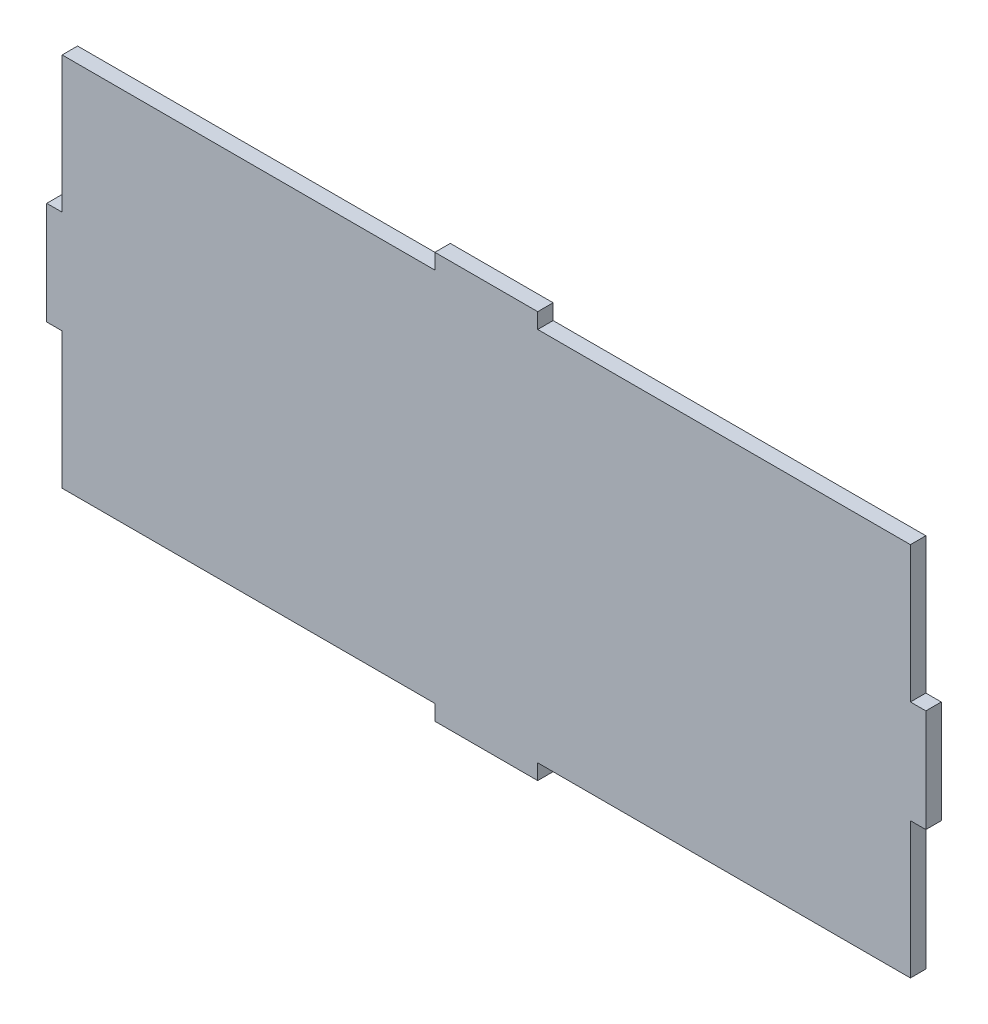
from build123d import *

# Parameters (mm, degrees)
ESBO_O1_W                = 165
ESBO_O1_H                = 73
ESBO_O1_W_2              = 20
ESBO_O1_H_2              = 3
ESBO_O1_W_3              = 3
ESBO_O1_H_3              = 20
RESSALTO_EXTRUS_O1_DEPTH = 3


with BuildPart() as part:
    # Esboço1 → Ressalto-extrusão1 (new body)
    with BuildSketch(Plane.XY):
        Rectangle(ESBO_O1_W, ESBO_O1_H)
        with Locations((0, 38)):
            Rectangle(ESBO_O1_W_2, ESBO_O1_H_2)
        with Locations((-84, 0)):
            Rectangle(ESBO_O1_W_3, ESBO_O1_H_3)
        with Locations((84, 0)):
            Rectangle(ESBO_O1_W_3, ESBO_O1_H_3)
        with Locations((0, -38)):
            Rectangle(ESBO_O1_W_2, ESBO_O1_H_2)
    extrude(amount=RESSALTO_EXTRUS_O1_DEPTH)


solid = part.part
